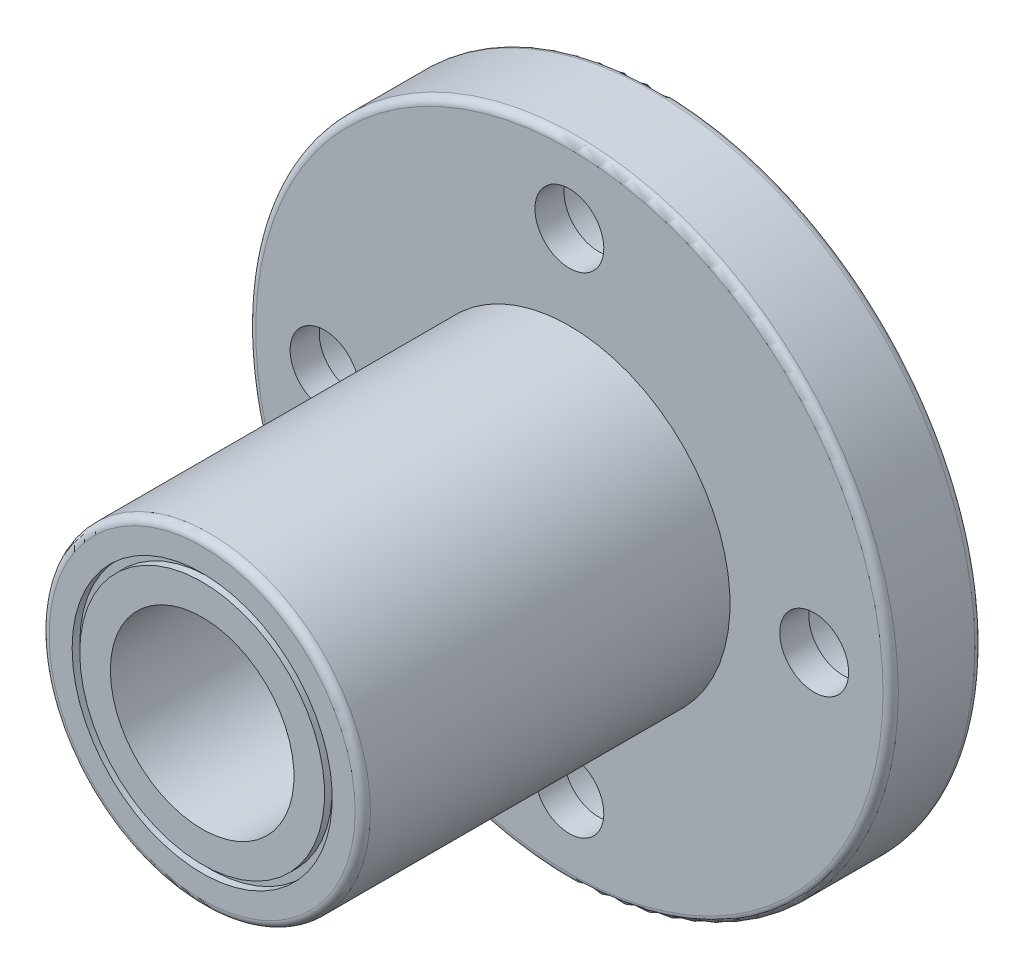
from build123d import *

# Parameters (mm, degrees)
PADR_OCIRCULAR1_COUNT = 4
FILETE1_R             = 0.5


with BuildPart() as part:
    # Esboço1 → Revolução1 (revolve)
    with BuildSketch(Plane(origin=(0, 0, 0), x_dir=(0, 0, -1), z_dir=(1, 0, 0)), mode=Mode.PRIVATE) as revolu_o1_sk:
        Polygon((0, 6), (0, 8), (-0.5, 8), (-0.5, 8.5), (0, 8.5), (0, 10), (-0.5, 10), (-0.5, 10.5), (0, 10.5), (0, 21), (-6, 21), (-6, 10.5), (-30, 10.5), (-30, 8.5), (-29.5, 8.5), (-29.5, 8), (-30, 8), (-30, 6), align=None)
    revolve(revolu_o1_sk.sketch.rotate(Axis((0, 0, 0), (0, 0, 1)), 90), axis=Axis((0, 0, 0), (0, 0, 1)))  # turned: the seam where the file's is

    # Esboço5 → Corte-Revolução1 (revolve, cut)
    with BuildSketch(Plane(origin=(0, 0, 0), x_dir=(0, 0, -1), z_dir=(1, 0, 0)), mode=Mode.PRIVATE) as corte_revolu_o1_sk:
        Polygon((0, 19.75), (-4.1, 19.75), (-4.1, 18.25), (-6, 18.25), (-6, 16), (0, 16), align=None)
    corte_revolu_o1 = revolve(corte_revolu_o1_sk.sketch.rotate(Axis((0, 16, 0), (0, 0, -1)), 180), axis=Axis((0, 16, 0), (0, 0, -1)), mode=Mode.SUBTRACT)  # turned: the seam where the file's is

    # PadrãoCircular1: Corte-Revolução1 ×4 about axis
    padr_ocircular1_axis = Axis((0, 0, 0), (0, 0, 1))
    for i in range(1, PADR_OCIRCULAR1_COUNT):
        add(corte_revolu_o1.rotate(padr_ocircular1_axis, i * 360 / PADR_OCIRCULAR1_COUNT), mode=Mode.SUBTRACT)

    # Filete1
    filete1_edges = [part.edges().sort_by_distance(p)[0] for p in [
        (10.5, 0, 30),
        (21, 0, 6),
        (21, 0, 0),
    ]]
    fillet(filete1_edges, radius=FILETE1_R)


solid = part.part
